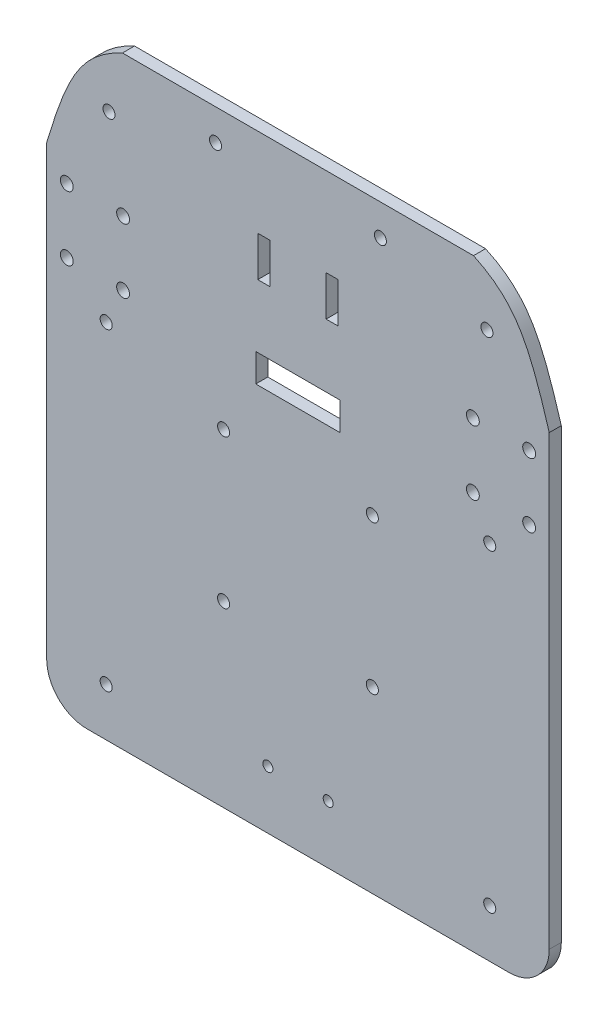
from build123d import *

# Parameters (mm, degrees)
SKETCH1_W           = 125
SKETCH1_H           = 150
BOSS_EXTRUDE1_DEPTH = 3
SKETCH2_R           = 1.6
CUT_EXTRUDE1_DEPTH  = 4
SKETCH3_R           = 1.5
CUT_EXTRUDE2_DEPTH  = 4
SKETCH4_R           = 1.25
CUT_EXTRUDE3_DEPTH  = 4
SKETCH5_W           = 3
SKETCH5_H           = 10
CUT_EXTRUDE4_DEPTH  = 4
SKETCH6_R           = 1.5
CUT_EXTRUDE5_DEPTH  = 4
CUT_EXTRUDE6_DEPTH  = 4
SKETCH8_R           = 1.5
CUT_EXTRUDE7_DEPTH  = 4.0000001
SKETCH9_R           = 1.5
CUT_EXTRUDE8_DEPTH  = 4.0000001
FILLET3_R           = 10
SKETCH10_W          = 21
SKETCH10_H          = 7
CUT_EXTRUDE9_DEPTH  = 4.0000001


with BuildPart() as part:
    # Sketch1 → Boss-Extrude1 (new body)
    with BuildSketch(Plane.XY):
        with Locations((62.5, 75)):
            Rectangle(SKETCH1_W, SKETCH1_H)
    extrude(amount=BOSS_EXTRUDE1_DEPTH)

    # Sketch2 → Cut-Extrude1 (cut, through all)
    with BuildSketch(Plane(origin=(0, 0, 0), x_dir=(-1, 0, 0), z_dir=(0, 0, -1))):
        with Locations((-120, 114.958148689)):
            Circle(SKETCH2_R)
        with Locations((-106, 114.958148689)):
            Circle(SKETCH2_R)
        with Locations((-106, 98.958148689)):
            Circle(SKETCH2_R)
        with Locations((-120, 98.958148689)):
            Circle(SKETCH2_R)
        with Locations((-19, 114.958148689)):
            Circle(SKETCH2_R)
        with Locations((-5, 114.958148689)):
            Circle(SKETCH2_R)
        with Locations((-5, 98.958148689)):
            Circle(SKETCH2_R)
        with Locations((-19, 98.958148689)):
            Circle(SKETCH2_R)
    extrude(amount=-CUT_EXTRUDE1_DEPTH, mode=Mode.SUBTRACT)

    # Sketch3 → Cut-Extrude2 (cut, through all)
    with BuildSketch(Plane(origin=(0, 0, 0), x_dir=(-1, 0, 0), z_dir=(0, 0, -1))):
        with BuildLine():
            ThreePointArc((-79.5, 81.5), (-82.060660172, 82.560660172), (-81, 80))
            Line((-81, 80), (-81, 81.5))
            Line((-81, 81.5), (-79.5, 81.5))
        make_face()
        with BuildLine():
            Line((-81, 81.5), (-81, 80))
            ThreePointArc((-81, 80), (-79.939339828, 80.439339828), (-79.5, 81.5))
            Line((-79.5, 81.5), (-81, 81.5))
        make_face()
        with Locations((-44, 81.5)):
            Circle(SKETCH3_R)
        with Locations((-81, 44.5)):
            Circle(SKETCH3_R)
        with Locations((-44, 44.5)):
            Circle(SKETCH3_R)
    extrude(amount=-CUT_EXTRUDE2_DEPTH, mode=Mode.SUBTRACT)

    # Sketch4 → Cut-Extrude3 (cut, through all)
    with BuildSketch(Plane(origin=(0, 0, 0), x_dir=(-1, 0, 0), z_dir=(0, 0, -1))):
        with Locations((-70.017473816, 14.43752637)):
            Circle(SKETCH4_R)
        with Locations((-55.017473816, 14.43752637)):
            Circle(SKETCH4_R)
    extrude(amount=-CUT_EXTRUDE3_DEPTH, mode=Mode.SUBTRACT)

    # Sketch5 → Cut-Extrude4 (cut, through all)
    with BuildSketch(Plane(origin=(0, 0, 0), x_dir=(-1, 0, 0), z_dir=(0, 0, -1))):
        with Locations((-54, 123.004295886)):
            Rectangle(SKETCH5_W, SKETCH5_H)
        with Locations((-71, 123.004295886)):
            Rectangle(SKETCH5_W, SKETCH5_H)
    extrude(amount=-CUT_EXTRUDE4_DEPTH, mode=Mode.SUBTRACT)

    # Sketch6 → Cut-Extrude5 (cut, through all)
    with BuildSketch(Plane(origin=(0, 0, 0), x_dir=(-1, 0, 0), z_dir=(0, 0, -1))):
        with Locations((-15.5, 135.678181118)):
            Circle(SKETCH6_R)
        with Locations((-109.5, 135.678181118)):
            Circle(SKETCH6_R)
    extrude(amount=-CUT_EXTRUDE5_DEPTH, mode=Mode.SUBTRACT)

    # Sketch7 → Cut-Extrude6 (cut, through all)
    with BuildSketch(Plane.XY.offset(3)):
        with BuildLine():
            Line((18.83856041, 150), (0, 150))
            Line((0, 150), (0, 121.303805561))
            add(Edge.make_bspline(
                [(0, 121.303805561), (5.130729703, 138.554109372), (8.057120528, 143.174726465), (13.293819899, 147.487302418), (18.83856041, 150)],
                knots=[0, 0, 0, 0, 0, 1, 1, 1, 1, 1], degree=4))
        make_face()
        with BuildLine():
            Line((125, 150), (125, 121.303805561))
            add(Edge.make_bspline(
                [(125, 121.303805561), (119.869270297, 138.554109372), (116.942879472, 143.174726465), (111.706180101, 147.487302418), (106.16143959, 150)],
                knots=[0, 0, 0, 0, 0, 1, 1, 1, 1, 1], degree=4))
            Line((106.16143959, 150), (125, 150))
        make_face()
    extrude(amount=-CUT_EXTRUDE6_DEPTH, mode=Mode.SUBTRACT)

    # Sketch8 → Cut-Extrude7 (cut, through all)
    with BuildSketch(Plane.XY.offset(3)):
        with Locations((14.8, 12)):
            Circle(SKETCH8_R)
        with Locations((110.2, 12)):
            Circle(SKETCH8_R)
        with Locations((14.8, 90)):
            Circle(SKETCH8_R)
        with Locations((110.2, 90)):
            Circle(SKETCH8_R)
    extrude(amount=-CUT_EXTRUDE7_DEPTH, mode=Mode.SUBTRACT)

    # Sketch9 → Cut-Extrude8 (cut, through all)
    with BuildSketch(Plane.XY.offset(3)):
        with Locations((42, 142.227223386)):
            Circle(SKETCH9_R)
        with Locations((83, 142.227223386)):
            Circle(SKETCH9_R)
    extrude(amount=-CUT_EXTRUDE8_DEPTH, mode=Mode.SUBTRACT)

    # Fillet3
    fillet3_edges = [part.edges().sort_by_distance(p)[0] for p in [
        (125, 0, 1.5),
        (0, 0, 1.5),
    ]]
    fillet(fillet3_edges, radius=FILLET3_R)

    # Sketch10 → Cut-Extrude9 (cut, through all)
    with BuildSketch(Plane.XY.offset(3)):
        with Locations((62.5, 98.783094858)):
            Rectangle(SKETCH10_W, SKETCH10_H)
    extrude(amount=-CUT_EXTRUDE9_DEPTH, mode=Mode.SUBTRACT)


solid = part.part
